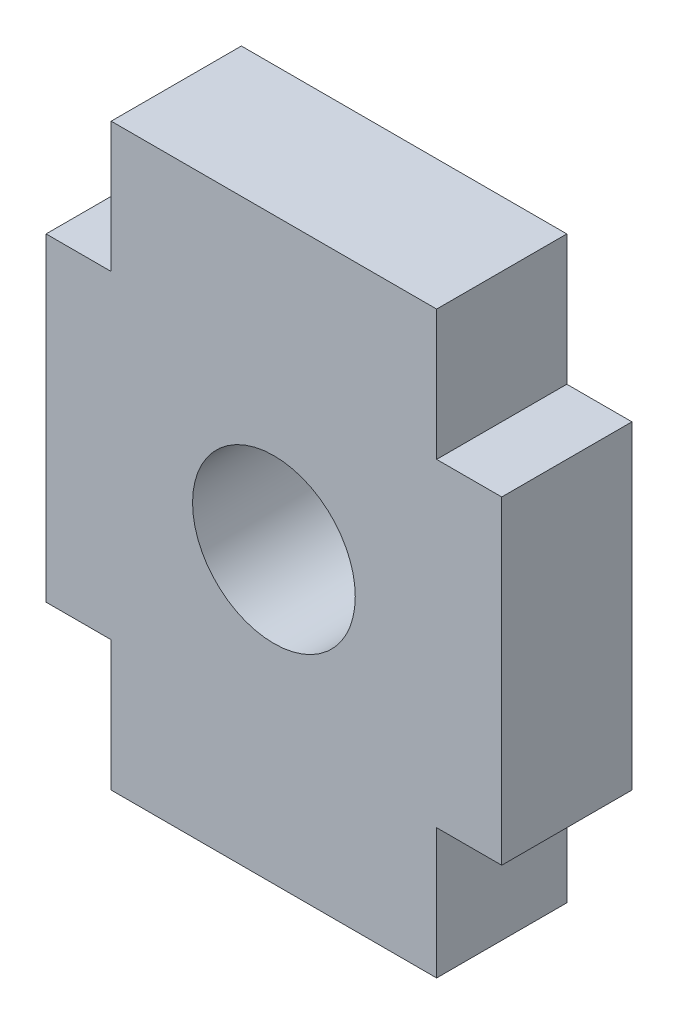
from build123d import *

# Parameters (mm, degrees)
SKETCH1_R           = 1.25
BOSS_EXTRUDE1_DEPTH = 2


with BuildPart() as part:
    # Sketch1 → Boss-Extrude1 (new body)
    with BuildSketch(Plane.XY):
        Polygon((1952.176808721, 1465.784115951), (1957.176808721, 1465.784115951), (1957.176808721, 1463.784115951), (1958.176808721, 1463.784115951), (1958.176808721, 1458.884115951), (1957.176808721, 1458.884115951), (1957.176808721, 1456.884115951), (1952.176808721, 1456.884115951), (1952.176808721, 1458.884115951), (1951.176808721, 1458.884115951), (1951.176808721, 1463.784115951), (1952.176808721, 1463.784115951), align=None)
        with Locations((1954.676808721, 1461.334115951)):
            Circle(SKETCH1_R, mode=Mode.SUBTRACT)
    extrude(amount=BOSS_EXTRUDE1_DEPTH)


solid = part.part
